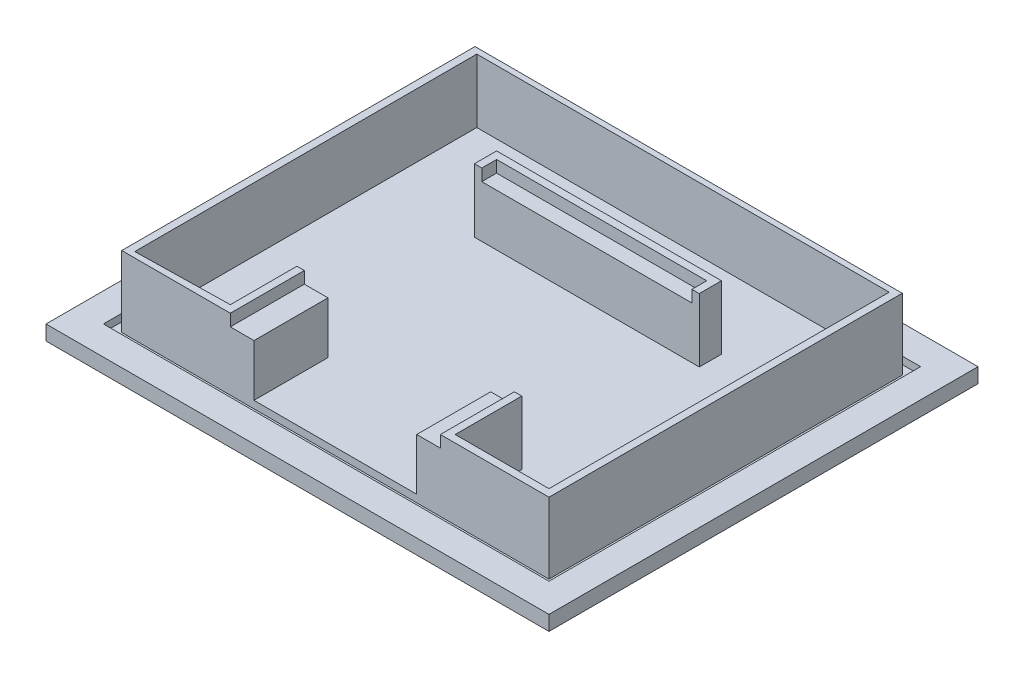
from build123d import *

# Parameters (mm, degrees)
SKETCH1_W           = 170
SKETCH1_H           = 145
BOSS_EXTRUDE1_DEPTH = 5
SKETCH2_W           = 150.6
SKETCH2_H           = 125.6
SKETCH2_W_2         = 144.4
SKETCH2_H_2         = 119.4
CUT_EXTRUDE1_DEPTH  = 2.5
SKETCH5_W           = 71
SKETCH5_H           = 7.5
SKETCH5_W_2         = 8
SKETCH5_H_2         = 25
BOSS_EXTRUDE2_DEPTH = 17.5
SKETCH6_W           = 2.5
SKETCH6_H           = 7.5
SKETCH6_H_2         = 25
BOSS_EXTRUDE3_DEPTH = 21.5
SKETCH7_W           = 71
SKETCH7_H           = 2.5
BOSS_EXTRUDE4_DEPTH = 4
BOSS_EXTRUDE6_DEPTH = 21.5


with BuildPart() as part:
    # Sketch1 → Boss-Extrude1 (new body)
    with BuildSketch(Plane(origin=(0, 0, 0), x_dir=(1, 0, 0), z_dir=(0, 1, 0))):
        Rectangle(SKETCH1_W, SKETCH1_H)
    extrude(amount=BOSS_EXTRUDE1_DEPTH)

    # Sketch2 → Cut-Extrude1 (cut)
    with BuildSketch(Plane(origin=(0, 5, 0), x_dir=(1, 0, 0), z_dir=(0, 1, 0))):
        Rectangle(SKETCH2_W, SKETCH2_H)
        Rectangle(SKETCH2_W_2, SKETCH2_H_2, mode=Mode.SUBTRACT)
    extrude(amount=-CUT_EXTRUDE1_DEPTH, mode=Mode.SUBTRACT)

    # Sketch5 → Boss-Extrude2 (add)
    with BuildSketch(Plane(origin=(0, 5, 0), x_dir=(1, 0, 0), z_dir=(0, 1, 0))):
        with Locations((0, 29.05)):
            Rectangle(SKETCH5_W, SKETCH5_H)
        with Locations((-31.5, -47.2)):
            Rectangle(SKETCH5_W_2, SKETCH5_H_2)
        with Locations((31.5, -47.2)):
            Rectangle(SKETCH5_W_2, SKETCH5_H_2)
    extrude(amount=BOSS_EXTRUDE2_DEPTH)

    # Sketch6 → Boss-Extrude3 (add)
    with BuildSketch(Plane(origin=(0, 5, 0), x_dir=(1, 0, 0), z_dir=(0, 1, 0))):
        with Locations((36.75, 29.05)):
            Rectangle(SKETCH6_W, SKETCH6_H)
        with Locations((-36.75, 29.05)):
            Rectangle(SKETCH6_W, SKETCH6_H)
        with Locations((36.75, -47.2)):
            Rectangle(SKETCH6_W, SKETCH6_H_2)
        with Locations((-36.75, -47.2)):
            Rectangle(SKETCH6_W, SKETCH6_H_2)
    extrude(amount=BOSS_EXTRUDE3_DEPTH)

    # Sketch7 → Boss-Extrude4 (add)
    with BuildSketch(Plane(origin=(0, 22.5, 0), x_dir=(1, 0, 0), z_dir=(0, 1, 0))):
        with Locations((0, 31.55)):
            Rectangle(SKETCH7_W, SKETCH7_H)
    extrude(amount=BOSS_EXTRUDE4_DEPTH)

    # Sketch9 → Boss-Extrude6 (add)
    with BuildSketch(Plane(origin=(0, 5, 0), x_dir=(1, 0, 0), z_dir=(0, 1, 0))):
        Polygon((38, -59.7), (72.2, -59.7), (72.2, -57.8), (72.2, 57.8), (72.2, 59.7), (-72.2, 59.7), (-72.2, 57.8), (-72.2, -57.8), (-72.2, -59.7), (-38, -59.7), (-38, -57.2), (-69.7, -57.8), (-69.7, 57.8), (69.7, 57.8), (69.7, -57.2), (38, -57.2), align=None)
    extrude(amount=BOSS_EXTRUDE6_DEPTH)


solid = part.part
